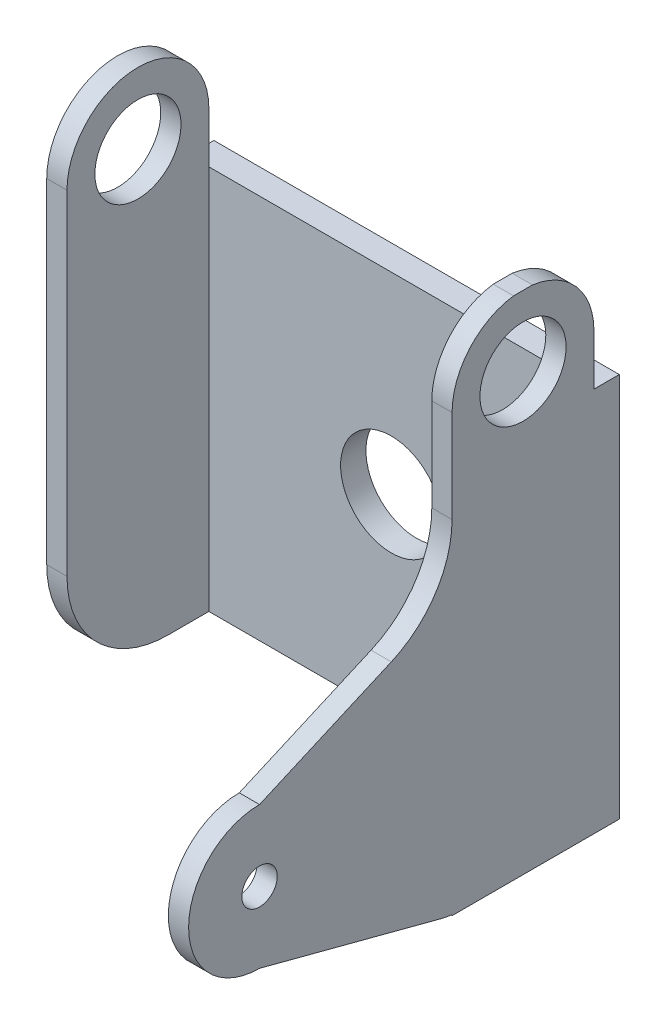
from build123d import *

# Parameters (mm, degrees)
SKETCH_1_W          = 40
SKETCH_1_H          = 38
SKETCH_1_R          = 5
EXTRUDE_1_DEPTH     = 2.5
EXTRUDE_2_DEPTH     = 14
SKETCH_3_R          = 4.25
CUT_EXTRUDE_2_DEPTH = 3
SKETCH_4_W          = 2
SKETCH_4_H          = 11.937460889
SKETCH_4_H_2        = 38
EXTRUDE_3_DEPTH     = 40
CUT_EXTRUDE_3_REACH = 42
SKETCH_5_R          = 1.75
SKETCH_5_R_2        = 4.25


with BuildPart() as part:
    # 草图1 → 凸台-拉伸1 (new body)
    with BuildSketch(Plane.XY):
        Rectangle(SKETCH_1_W, SKETCH_1_H)
        Circle(SKETCH_1_R, mode=Mode.SUBTRACT)
    extrude(amount=EXTRUDE_1_DEPTH)

    # 草图2 → 凸台-拉伸2 (add)
    with BuildSketch(Plane.XY.offset(2.5)):
        Polygon((-18, 19), (-18, -19), (-20, -19), (-20, 19), (-20, 31), (-18, 31), align=None)
    extrude(amount=EXTRUDE_2_DEPTH)

    # 草图3 → 切除-拉伸2 (cut, through all)
    with BuildSketch(Plane(origin=(-18, 0, 0), x_dir=(0, 0, -1), z_dir=(1, 0, 0))):
        with BuildLine():
            Line((-16.5, -19), (-6.5, -19))
            ThreePointArc((-6.5, -19), (-13.571067812, -16.071067812), (-16.5, -9))
            Line((-16.5, -9), (-16.5, -19))
        make_face()
        with BuildLine():
            Line((-16.5, 31), (-16.5, 24))
            ThreePointArc((-16.5, 24), (-14.449747468, 28.949747468), (-9.5, 31))
            Line((-9.5, 31), (-16.5, 31))
        make_face()
        with BuildLine():
            ThreePointArc((-9.5, 31), (-4.550252532, 28.949747468), (-2.5, 24))
            Line((-2.5, 24), (-2.5, 31))
            Line((-2.5, 31), (-9.5, 31))
        make_face()
        with Locations((-9.5, 24)):
            Circle(SKETCH_3_R)
    extrude(amount=-CUT_EXTRUDE_2_DEPTH, mode=Mode.SUBTRACT)

    # 草图4 → 凸台-拉伸3 (add)
    with BuildSketch(Plane.XY.offset(2.5)):
        with Locations((19, 24.968730445)):
            Rectangle(SKETCH_4_W, SKETCH_4_H)
        with Locations((19, 0)):
            Rectangle(SKETCH_4_W, SKETCH_4_H_2)
    extrude(amount=EXTRUDE_3_DEPTH)

    # 草图5 → 切除-拉伸3 (cut, up to next)
    with BuildSketch(Plane(origin=(20, 0, 0), x_dir=(0, 0, -1), z_dir=(1, 0, 0)), mode=Mode.PRIVATE) as cut_extrude_3_sk1:
        with BuildLine():
            ThreePointArc((-35.5, -14), (-40.449747452, -11.949747484), (-42.5, -7.000000045))
            Line((-42.5, -7.000000045), (-42.5, -19))
            Line((-42.5, -19), (-16.5, -19))
            Line((-16.5, -19), (-16.5, -18.915955378))
            ThreePointArc((-16.5, -18.915955378), (-17.129495713, -18.813310688), (-17.751167584, -18.670745373))
            Line((-17.751167584, -18.670745373), (-35.5, -14))
        make_face()
    cut_extrude_3_tool1 = extrude(cut_extrude_3_sk1.sketch, amount=-CUT_EXTRUDE_3_REACH, mode=Mode.PRIVATE) & part.part
    add(cut_extrude_3_tool1.solids().sort_by_distance((20, -16.467085, 34.190758))[0], mode=Mode.SUBTRACT)
    # 草图5 → 切除-拉伸3 (cut, up to next)
    with BuildSketch(Plane(origin=(20, 0, 0), x_dir=(0, 0, -1), z_dir=(1, 0, 0)), mode=Mode.PRIVATE) as cut_extrude_3_sk2:
        with BuildLine():
            ThreePointArc((-16.5, 24), (-14.769502014, 28.60785726), (-10.433614706, 30.937460889))
            Line((-10.433614706, 30.937460889), (-42.5, 30.937460889))
            Line((-42.5, 30.937460889), (-42.5, -7.000000045))
            ThreePointArc((-42.5, -7.000000045), (-40.449747484, -2.050252548), (-35.5, 0))
            Line((-35.5, 0), (-22.492126933, 5.690411164))
            ThreePointArc((-22.492126933, 5.690411164), (-18.131047537, 9.37849159), (-16.5, 14.852122439))
            Line((-16.5, 14.852122439), (-16.5, 24))
        make_face()
    cut_extrude_3_tool2 = extrude(cut_extrude_3_sk2.sketch, amount=-CUT_EXTRUDE_3_REACH, mode=Mode.PRIVATE) & part.part
    add(cut_extrude_3_tool2.solids().sort_by_distance((20, 16.838407, 30.295804))[0], mode=Mode.SUBTRACT)
    # 草图5 → 切除-拉伸3 (cut, up to next)
    with BuildSketch(Plane(origin=(20, 0, 0), x_dir=(0, 0, -1), z_dir=(1, 0, 0)), mode=Mode.PRIVATE) as cut_extrude_3_sk3:
        with BuildLine():
            Line((-2.5, 24), (-2.5, 25))
            Line((-2.5, 25), (-2.5, 30.937460889))
            Line((-2.5, 30.937460889), (-8.566385294, 30.937460889))
            ThreePointArc((-8.566385294, 30.937460889), (-4.230497986, 28.60785726), (-2.5, 24))
        make_face()
    cut_extrude_3_tool3 = extrude(cut_extrude_3_sk3.sketch, amount=-CUT_EXTRUDE_3_REACH, mode=Mode.PRIVATE) & part.part
    add(cut_extrude_3_tool3.solids().sort_by_distance((20, 29.375995, 3.999369))[0], mode=Mode.SUBTRACT)
    # 草图5 → 切除-拉伸3 (cut, up to next)
    with BuildSketch(Plane(origin=(20, 0, 0), x_dir=(0, 0, -1), z_dir=(1, 0, 0)), mode=Mode.PRIVATE) as cut_extrude_3_sk4:
        with Locations((-35.5, -7)):
            Circle(SKETCH_5_R)
    cut_extrude_3_tool4 = extrude(cut_extrude_3_sk4.sketch, amount=-CUT_EXTRUDE_3_REACH, mode=Mode.PRIVATE) & part.part
    add(cut_extrude_3_tool4.solids().sort_by_distance((20, -7, 35.5))[0], mode=Mode.SUBTRACT)
    # 草图5 → 切除-拉伸3 (cut, up to next)
    with BuildSketch(Plane(origin=(20, 0, 0), x_dir=(0, 0, -1), z_dir=(1, 0, 0)), mode=Mode.PRIVATE) as cut_extrude_3_sk5:
        with Locations((-9.5, 24)):
            Circle(SKETCH_5_R_2)
    cut_extrude_3_tool5 = extrude(cut_extrude_3_sk5.sketch, amount=-CUT_EXTRUDE_3_REACH, mode=Mode.PRIVATE) & part.part
    add(cut_extrude_3_tool5.solids().sort_by_distance((20, 24, 9.5))[0], mode=Mode.SUBTRACT)


solid = part.part
